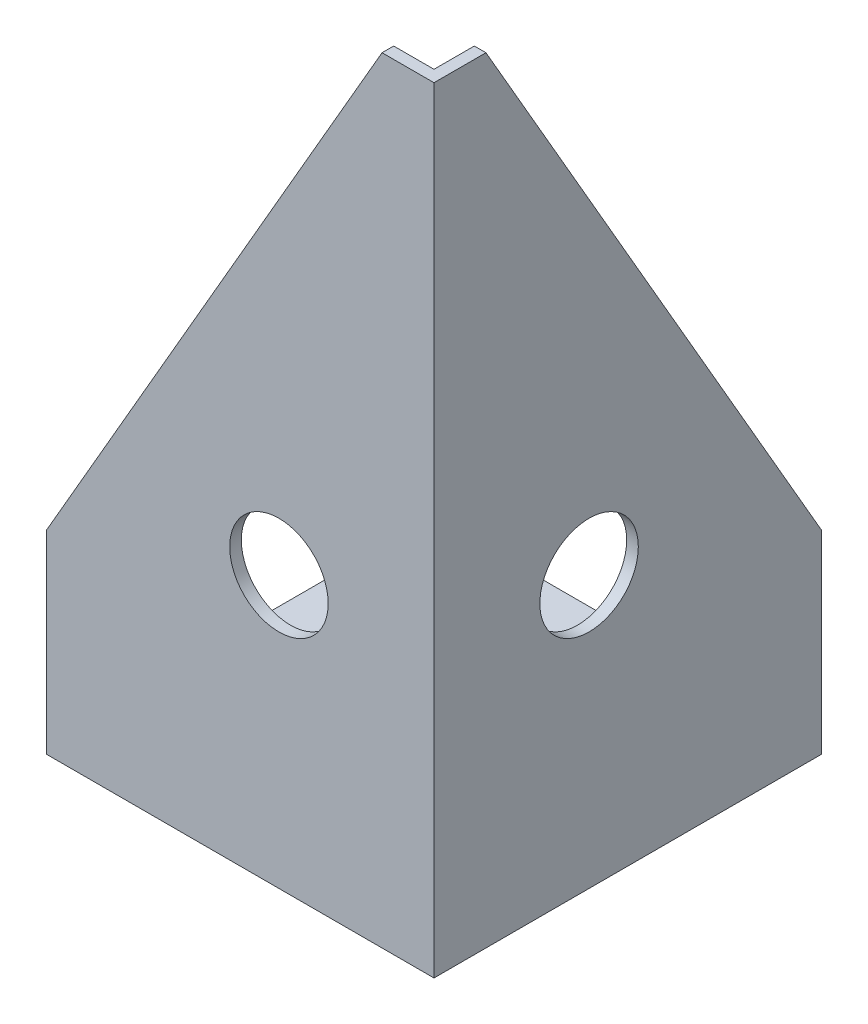
from build123d import *

# Parameters (mm, degrees)
SKIZZE1_W                       = 100
SKIZZE1_H                       = 100
AUFSATZ_LINEAR_AUSTRAGEN1_DEPTH = 200
WANDUNG1_T                      = -3
FASE1_SIZE                      = 150
FASE1_SIZE2                     = 86.602540378
FASE1_PART_2_SIZE               = 150
FASE1_PART_2_SIZE2              = 86.602540378
BOHRUNG1_D                      = 25.4
BOHRUNG1_DEPTH                  = 3
BOHRUNG1_ON_FACE_2_D            = 25.4
BOHRUNG1_ON_FACE_2_DEPTH        = 3
DURCHGANGSLOCH_F_R_M101_D       = 11
DURCHGANGSLOCH_F_R_M101_DEPTH   = 3


with BuildPart() as part:
    # Skizze1 → Aufsatz-Linear austragen1 (new body)
    with BuildSketch(Plane(origin=(0, 0, 0), x_dir=(1, 0, 0), z_dir=(0, 1, 0))):
        with Locations((50, 50)):
            Rectangle(SKIZZE1_W, SKIZZE1_H)
    extrude(amount=AUFSATZ_LINEAR_AUSTRAGEN1_DEPTH)

    # Wandung1
    wandung1_openings = [part.faces().sort_by_distance(p)[0] for p in [
        (50, 200, -50),
        (50, 100, -100),
        (0, 100, -50),
    ]]
    offset(amount=WANDUNG1_T, openings=wandung1_openings, kind=Kind.INTERSECTION)

    # Fase1
    fase1_edges = [part.edges().sort_by_distance(p)[0] for p in [
        (98.5, 200, -100),
    ]]
    fase1_side = [part.faces().sort_by_distance(p)[0] for p in [
        (98.5, 197.763932023, -100),
    ]]
    chamfer(fase1_edges, length=FASE1_SIZE, length2=FASE1_SIZE2, reference=fase1_side[0])

    # Fase1 part 2
    fase1_part_2_edges = [part.edges().sort_by_distance(p)[0] for p in [
        (0, 200, -1.5),
    ]]
    fase1_part_2_side = [part.faces().sort_by_distance(p)[0] for p in [
        (0, 1.5, -97.763932023),
    ]]
    chamfer(fase1_part_2_edges, length=FASE1_PART_2_SIZE, length2=FASE1_PART_2_SIZE2, reference=fase1_part_2_side[0])

    # Bohrung1
    with Locations(Plane(origin=(100, 70, -40), x_dir=(0, 0, 1), z_dir=(1, 0, 0))):
        with Locations((0, 0)):
            Hole(BOHRUNG1_D / 2, depth=BOHRUNG1_DEPTH)

    # Bohrung1 on face 2
    with Locations(Plane(origin=(60, 70, 0), x_dir=(1, 0, 0), z_dir=(0, 0, 1))):
        with Locations((0, 0)):
            Hole(BOHRUNG1_ON_FACE_2_D / 2, depth=BOHRUNG1_ON_FACE_2_DEPTH)

    # Durchgangsloch für M101
    with Locations(Plane(origin=(0, 0, 0), x_dir=(-1, 0, 0), z_dir=(0, -1, 0))):
        with Locations((-90, 90), (-90, 10), (-60, 10), (-10, 10)):
            Hole(DURCHGANGSLOCH_F_R_M101_D / 2, depth=DURCHGANGSLOCH_F_R_M101_DEPTH)


solid = part.part
